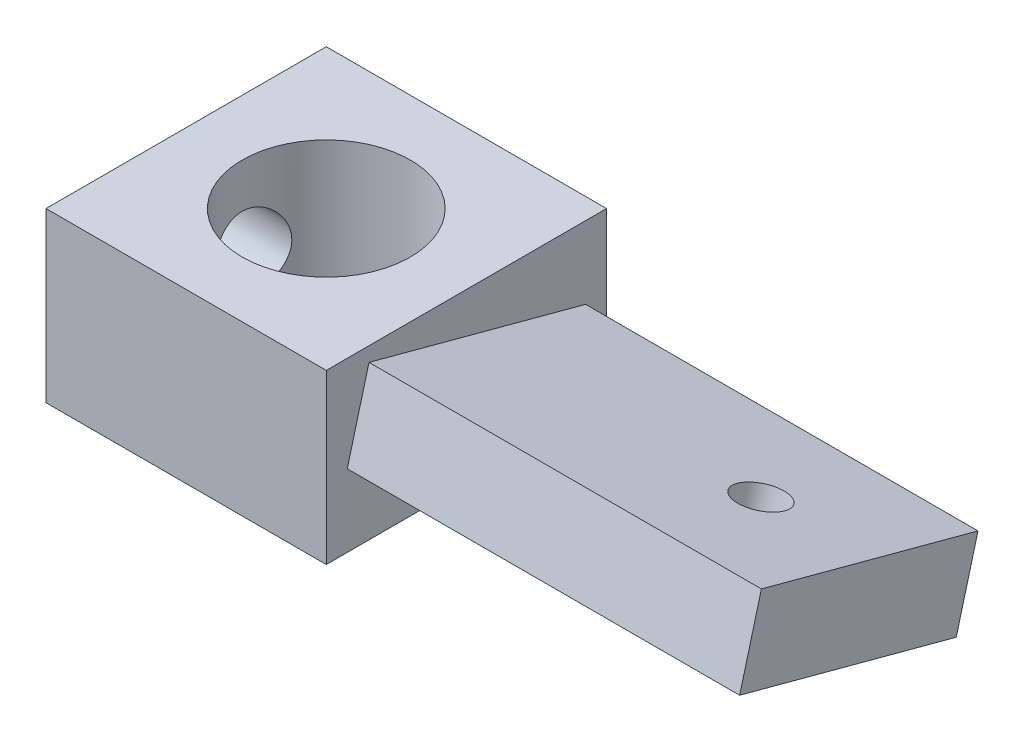
from build123d import *

# Parameters (mm, degrees)
SKETCH1_W                    = 15.875
SKETCH1_H                    = 9.525
BOSS_EXTRUDE1_DEPTH          = 7.9375
BOSS_EXTRUDE2_DEPTH          = 22.225
F_3_8_0_375_DIAMETER_HOLE1_D = 9.525
F_6_32_TAPPED_HOLE1_D        = 2.7051
F_8_CLEARANCE_HOLE1_D        = 4.4958
F_8_CLEARANCE_HOLE1_DEPTH    = 19.05
F_8_CLEARANCE_HOLE1_TIP      = 1.350674586


with BuildPart() as part:
    # Sketch1 → Boss-Extrude1 (new body, symmetric)
    with BuildSketch(Plane(origin=(0, 0, 0), x_dir=(0, 0, -1), z_dir=(1, 0, 0))):
        Rectangle(SKETCH1_W, SKETCH1_H)
    extrude(amount=BOSS_EXTRUDE1_DEPTH, both=True)

    # Sketch2 → Boss-Extrude2 (add)
    with BuildSketch(Plane(origin=(7.9375, 0, 0), x_dir=(0, 0, -1), z_dir=(1, 0, 0))):
        Polygon((-6.749941848, -0.656609937), (5.517316146, -3.94361181), (6.749941848, 0.656609937), (-5.517316146, 3.94361181), align=None)
    extrude(amount=BOSS_EXTRUDE2_DEPTH)

    # 3/8 (0.375) Diameter Hole1 (through all)
    with Locations(Plane(origin=(0, 4.7625, 0), x_dir=(1, 0, 0), z_dir=(0, 1, 0))):
        with Locations((0, 0)):
            Hole(F_3_8_0_375_DIAMETER_HOLE1_D / 2)

    # #6-32 Tapped Hole1 (through all)
    with Locations(Plane(origin=(0, 2.300110874, -0.616312851), x_dir=(1, 0, 0), z_dir=(0, 0.965925826, -0.258819045))):
        with Locations((24, 0)):
            Hole(F_6_32_TAPPED_HOLE1_D / 2)

    # #8 Clearance Hole1
    with Locations(Plane(origin=(-7.9375, 0, 0), x_dir=(0, 0, -1), z_dir=(-1, 0, 0))):
        with Locations((0, 0)):
            Hole(F_8_CLEARANCE_HOLE1_D / 2, depth=F_8_CLEARANCE_HOLE1_DEPTH)
            with Locations((0, 0, -(F_8_CLEARANCE_HOLE1_DEPTH + F_8_CLEARANCE_HOLE1_TIP / 2))):  # 118° drill point
                Cone(0, F_8_CLEARANCE_HOLE1_D / 2, F_8_CLEARANCE_HOLE1_TIP, mode=Mode.SUBTRACT)


solid = part.part
